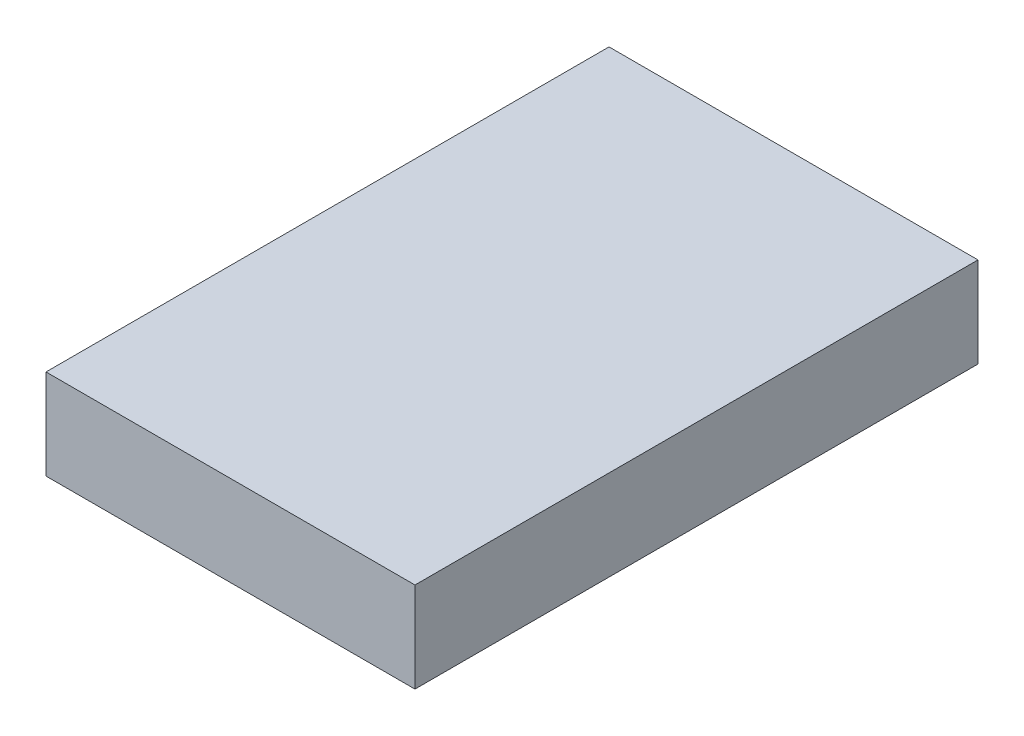
from build123d import *

# Parameters (mm, degrees)
SKETCH1_W           = 135
SKETCH1_H           = 206
BOSS_EXTRUDE1_DEPTH = 33


with BuildPart() as part:
    # Sketch1 → Boss-Extrude1 (new body)
    with BuildSketch(Plane(origin=(0, 0, 0), x_dir=(1, 0, 0), z_dir=(0, 1, 0))):
        with Locations((67.5, 103)):
            Rectangle(SKETCH1_W, SKETCH1_H)
    extrude(amount=BOSS_EXTRUDE1_DEPTH)


solid = part.part
